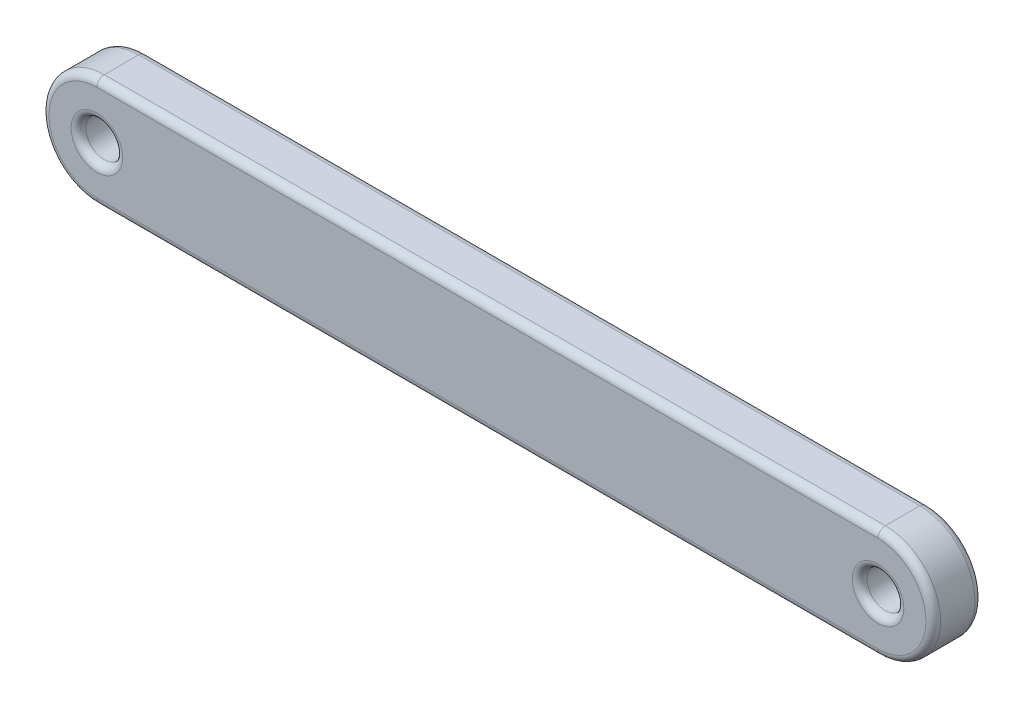
from build123d import *

# Parameters (mm, degrees)
SKETCH1_R           = 0.75
BOSS_EXTRUDE1_DEPTH = 2
FILLET1_R           = 0.3


with BuildPart() as part:
    # Sketch1 → Boss-Extrude1 (new body)
    with BuildSketch(Plane.XY):
        with BuildLine():
            Line((0, 2.25), (31.82825623, 2.25))
            ThreePointArc((31.82825623, 2.25), (34.07825623, 0), (31.82825623, -2.25))
            Line((31.82825623, -2.25), (0, -2.25))
            ThreePointArc((0, -2.25), (-2.25, 0), (0, 2.25))
        make_face()
        Circle(SKETCH1_R, mode=Mode.SUBTRACT)
        with Locations((31.82825623, 0)):
            Circle(SKETCH1_R, mode=Mode.SUBTRACT)
    extrude(amount=BOSS_EXTRUDE1_DEPTH)

    # Fillet1
    fillet1_edges = [part.edges().sort_by_distance(p)[0] for p in [
        (34.07825623, 0, 2),
        (-0.75, 0, 0),
        (-0.75, 0, 2),
        (15.914128115, 2.25, 2),
        (31.07825623, 0, 0),
        (31.07825623, 0, 2),
        (-2.25, 0, 2),
        (15.914128115, 2.25, 0),
        (34.07825623, 0, 0),
        (15.914128115, -2.25, 0),
        (-2.25, 0, 0),
        (15.914128115, -2.25, 2),
    ]]
    fillet(fillet1_edges, radius=FILLET1_R)


solid = part.part
